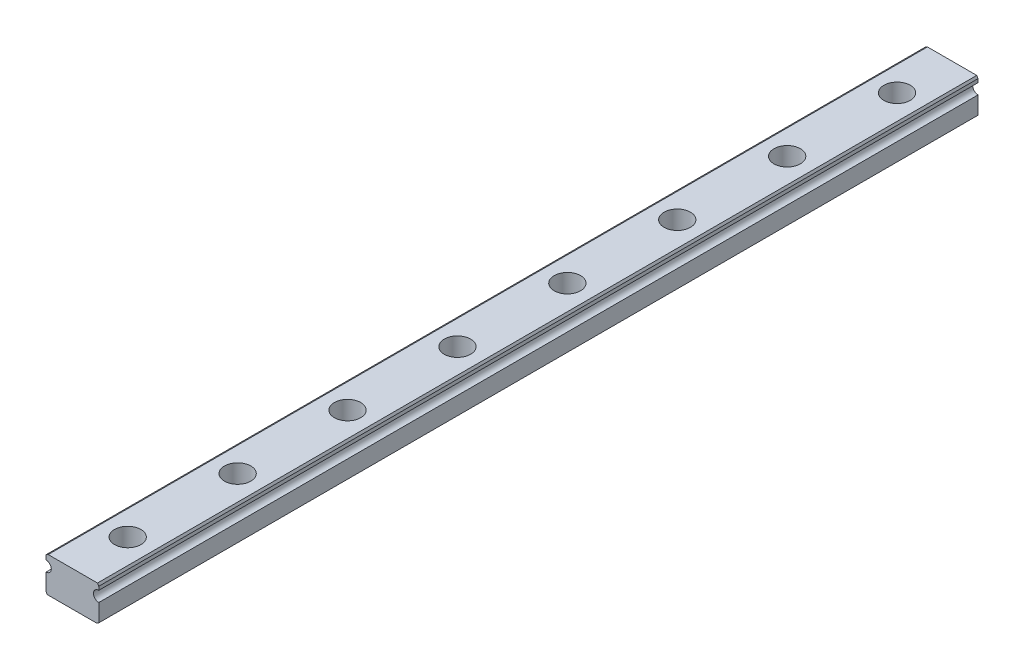
from build123d import *

# Parameters (mm, degrees)
BOSS_EXTRUDE1_DEPTH   = 100
CHAMFER1_SIZE         = 0.5
CHAMFER1_SIZE2        = 0.288675135
CHAMFER1_PART_2_SIZE  = 0.5
CHAMFER1_PART_2_SIZE2 = 0.288675135
CHAMFER1_PART_3_SIZE  = 0.5
CHAMFER1_PART_3_SIZE2 = 0.288675135
CHAMFER1_PART_4_SIZE  = 0.5
CHAMFER1_PART_4_SIZE2 = 0.288675135
SKETCH2_R             = 1.75
CUT_EXTRUDE1_DEPTH    = 8
SKETCH3_R             = 3
CUT_EXTRUDE2_DEPTH    = 4.5
LPATTERN1_COUNT       = 8
LPATTERN1_PITCH       = 25


with BuildPart() as part:
    # Sketch1 → Boss-Extrude1 (new body, symmetric)
    with BuildSketch(Plane.XY):
        with BuildLine():
            Line((-6, -4), (6, -4))
            Line((6, -4), (6, 0.3))
            ThreePointArc((6, 0.3), (4.8, 1.5), (6, 2.7))
            Line((6, 2.7), (6, 4))
            Line((6, 4), (-6, 4))
            Line((-6, 4), (-6, 2.7))
            ThreePointArc((-6, 2.7), (-4.8, 1.5), (-6, 0.3))
            Line((-6, 0.3), (-6, -4))
        make_face()
    extrude(amount=BOSS_EXTRUDE1_DEPTH, both=True)

    # Chamfer1
    chamfer1_edges = [part.edges().sort_by_distance(p)[0] for p in [
        (6, -4, 0),
    ]]
    chamfer1_side = [part.faces().sort_by_distance(p)[0] for p in [
        (0, -4, 0),
    ]]
    chamfer(chamfer1_edges, length=CHAMFER1_SIZE, length2=CHAMFER1_SIZE2, reference=chamfer1_side[0])

    # Chamfer1 part 2
    chamfer1_part_2_edges = [part.edges().sort_by_distance(p)[0] for p in [
        (-6, -4, 0),
    ]]
    chamfer1_part_2_side = [part.faces().sort_by_distance(p)[0] for p in [
        (-6, -1.85, 0),
    ]]
    chamfer(chamfer1_part_2_edges, length=CHAMFER1_PART_2_SIZE, length2=CHAMFER1_PART_2_SIZE2, reference=chamfer1_part_2_side[0])

    # Chamfer1 part 3
    chamfer1_part_3_edges = [part.edges().sort_by_distance(p)[0] for p in [
        (-6, 4, 0),
    ]]
    chamfer1_part_3_side = [part.faces().sort_by_distance(p)[0] for p in [
        (0, 4, 0),
    ]]
    chamfer(chamfer1_part_3_edges, length=CHAMFER1_PART_3_SIZE, length2=CHAMFER1_PART_3_SIZE2, reference=chamfer1_part_3_side[0])

    # Chamfer1 part 4
    chamfer1_part_4_edges = [part.edges().sort_by_distance(p)[0] for p in [
        (6, 4, 0),
    ]]
    chamfer1_part_4_side = [part.faces().sort_by_distance(p)[0] for p in [
        (6, 3.35, 0),
    ]]
    chamfer(chamfer1_part_4_edges, length=CHAMFER1_PART_4_SIZE, length2=CHAMFER1_PART_4_SIZE2, reference=chamfer1_part_4_side[0])

    # Sketch2 → Cut-Extrude1 (cut)
    with BuildSketch(Plane(origin=(0, 4, 0), x_dir=(1, 0, 0), z_dir=(0, 1, 0))):
        with Locations((0.092454629, -87.5)):
            Circle(SKETCH2_R)
    cut_extrude1 = extrude(amount=-CUT_EXTRUDE1_DEPTH, mode=Mode.SUBTRACT)

    # Sketch3 → Cut-Extrude2 (cut)
    with BuildSketch(Plane(origin=(0, 4, 0), x_dir=(1, 0, 0), z_dir=(0, 1, 0))):
        with Locations((0.092454629, -87.5)):
            Circle(SKETCH3_R)
    cut_extrude2 = extrude(amount=-CUT_EXTRUDE2_DEPTH, mode=Mode.SUBTRACT)

    # LPattern1: Cut-Extrude1, Cut-Extrude2 ×8
    with Locations(*[(0, 0, -i * LPATTERN1_PITCH) for i in range(1, LPATTERN1_COUNT)]):
        add(cut_extrude1, mode=Mode.SUBTRACT)
        add(cut_extrude2, mode=Mode.SUBTRACT)


solid = part.part
